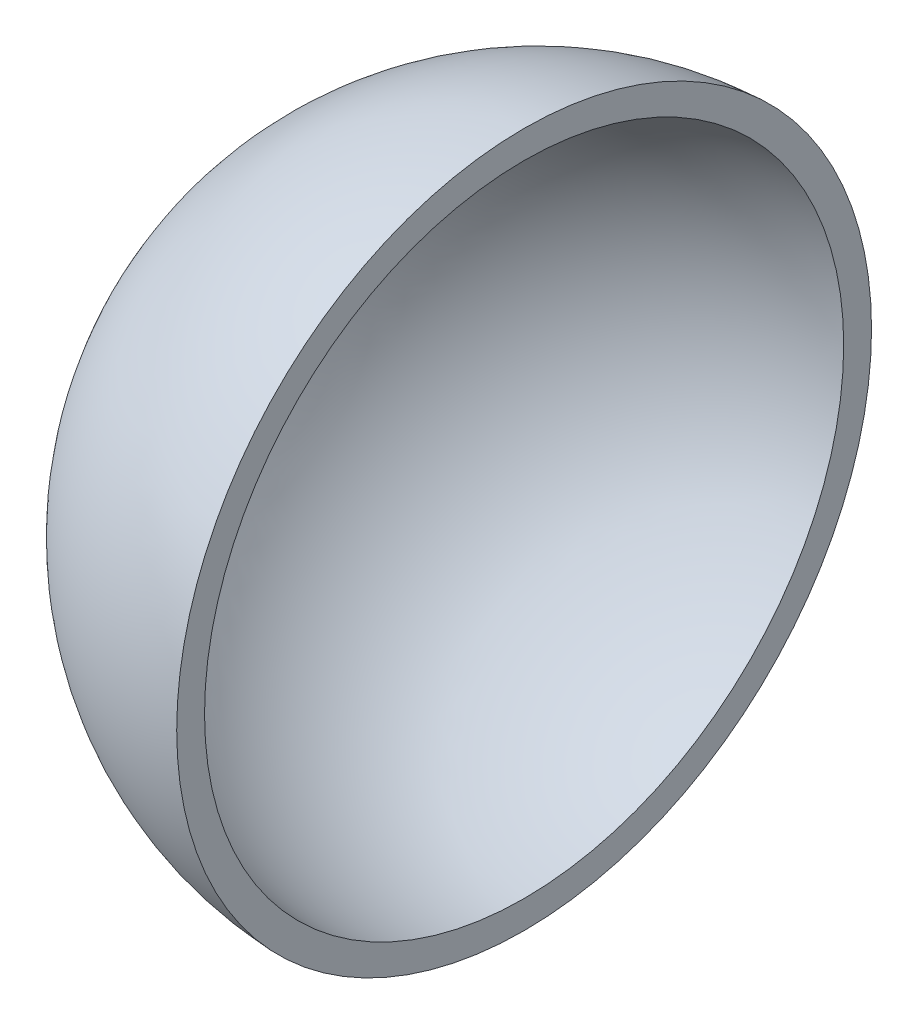
from build123d import *


with BuildPart() as part:
    # 草图1 → 旋转1 (revolve)
    with BuildSketch(Plane(origin=(0, 0, 0), x_dir=(1, 0, 0), z_dir=(0, 1, 0))):
        with BuildLine():
            Line((-23, 0), (-25, 0))
            ThreePointArc((-25, 0), (-18.027756377, -17.320508076), (-1, -24.979991994))
            Line((-1, -24.979991994), (-1, -22.978250586))
            ThreePointArc((-1, -22.978250586), (-16.613247726, -15.905973721), (-23, 0))
        make_face()
    revolve(axis=Axis((0, 0, 0), (-1, 0, 0)))


solid = part.part
